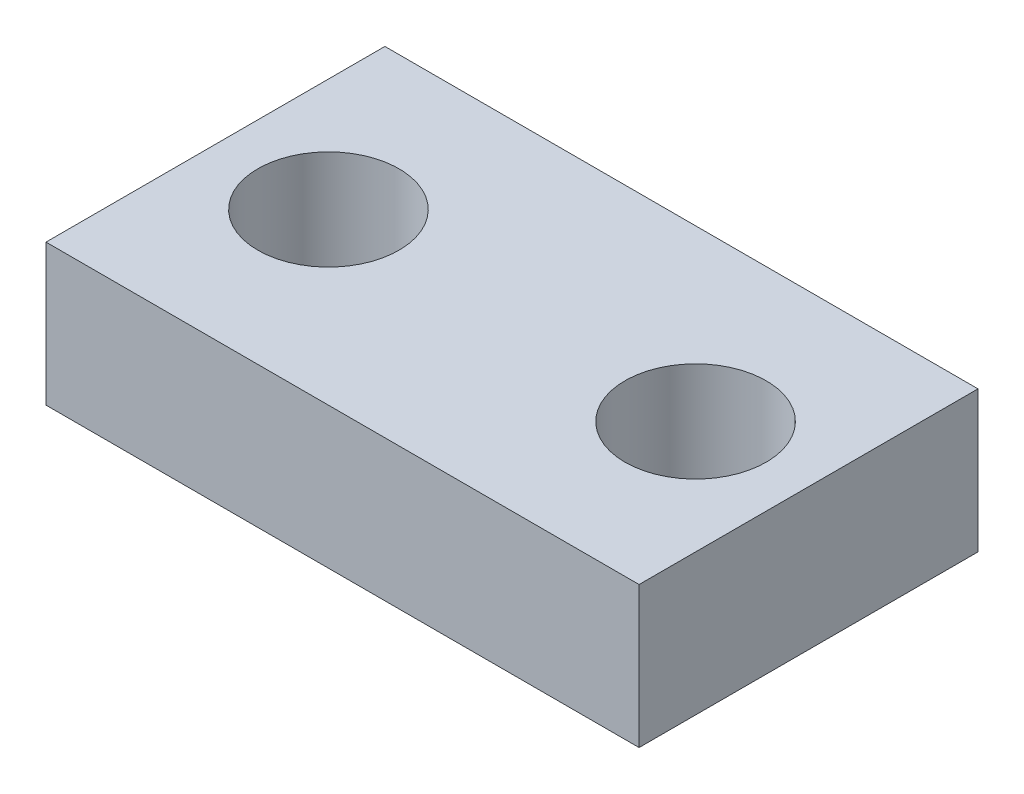
from build123d import *

# Parameters (mm, degrees)
SKETCH2_W           = 66.675
SKETCH2_H           = 38.1
BOSS_EXTRUDE1_DEPTH = 15.875
SKETCH3_R           = 7.9375
CUT_EXTRUDE1_DEPTH  = 16.875


with BuildPart() as part:
    # Sketch2 → Boss-Extrude1 (new body)
    with BuildSketch(Plane(origin=(0, 0, 0), x_dir=(1, 0, 0), z_dir=(0, 1, 0))):
        Rectangle(SKETCH2_W, SKETCH2_H)
    extrude(amount=BOSS_EXTRUDE1_DEPTH)

    # Sketch3 → Cut-Extrude1 (cut, through all)
    with BuildSketch(Plane(origin=(0, 15.875, 0), x_dir=(1, 0, 0), z_dir=(0, 1, 0))):
        with Locations((-20.6375, 0)):
            Circle(SKETCH3_R)
        with Locations((20.6375, 0)):
            Circle(SKETCH3_R)
    extrude(amount=-CUT_EXTRUDE1_DEPTH, mode=Mode.SUBTRACT)


solid = part.part
